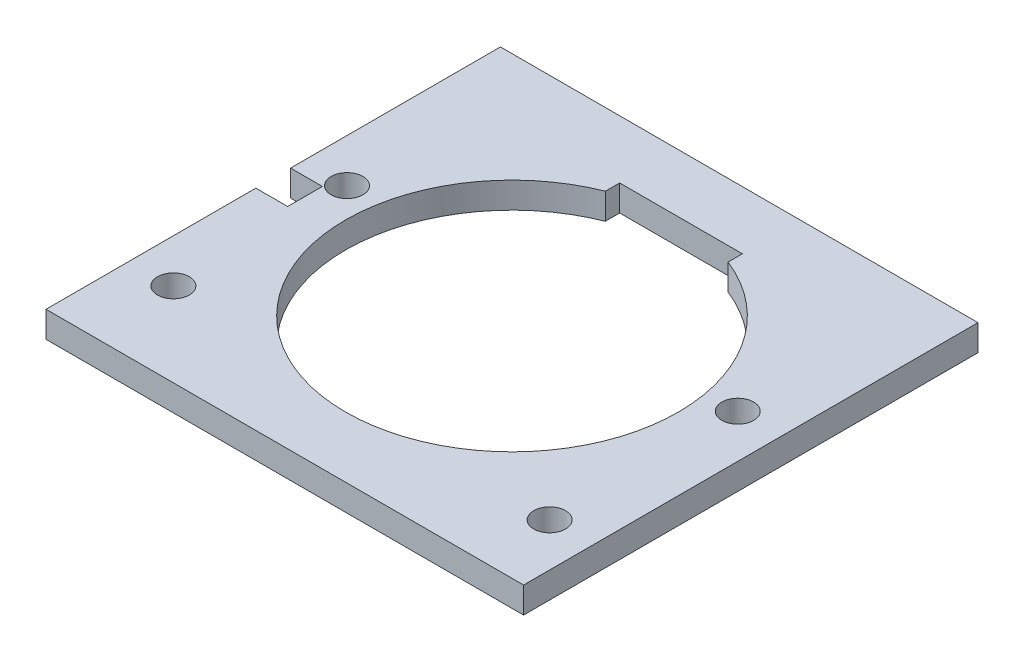
from build123d import *

# Parameters (mm, degrees)
SKETCH5_W      = 41.91
SKETCH5_H      = 39.878
SKETCH5_R      = 1.397
EXTRUDE3_DEPTH = 2.286
SKETCH6_W      = 10.7696
SKETCH6_H      = 20.1676
EXTRUDE4_DEPTH = 3.286
SKETCH7_R      = 14.605
SKETCH7_W      = 2.794
SKETCH7_H      = 3.048
EXTRUDE5_DEPTH = 3.286


with BuildPart() as part:
    # Sketch5 → Extrude3 (new body)
    with BuildSketch(Plane(origin=(0, 0, 0), x_dir=(1, 0, 0), z_dir=(0, 1, 0))):
        with Locations((-20.955, -19.939)):
            Rectangle(SKETCH5_W, SKETCH5_H)
        with Locations((-38.1, -17.272)):
            Circle(SKETCH5_R, mode=Mode.SUBTRACT)
        with Locations((-38.1, -32.512)):
            Circle(SKETCH5_R, mode=Mode.SUBTRACT)
        with Locations((-3.81, -33.782)):
            Circle(SKETCH5_R, mode=Mode.SUBTRACT)
        with Locations((-3.81, -17.272)):
            Circle(SKETCH5_R, mode=Mode.SUBTRACT)
    extrude(amount=EXTRUDE3_DEPTH)

    # Sketch6 → Extrude4 (cut, through all)
    with BuildSketch(Plane(origin=(0, 2.286, 0), x_dir=(-1, 0, 0), z_dir=(0, 1, 0))):
        with Locations((20.955, 15.1892)):
            Rectangle(SKETCH6_W, SKETCH6_H)
    extrude(amount=-EXTRUDE4_DEPTH, mode=Mode.SUBTRACT)

    # Sketch7 → Extrude5 (cut, through all)
    with BuildSketch(Plane.XZ):
        with Locations((-20.955, 19.939)):
            Circle(SKETCH7_R)
        with Locations((-40.513, 19.939)):
            Rectangle(SKETCH7_W, SKETCH7_H)
    extrude(amount=-EXTRUDE5_DEPTH, mode=Mode.SUBTRACT)


solid = part.part
